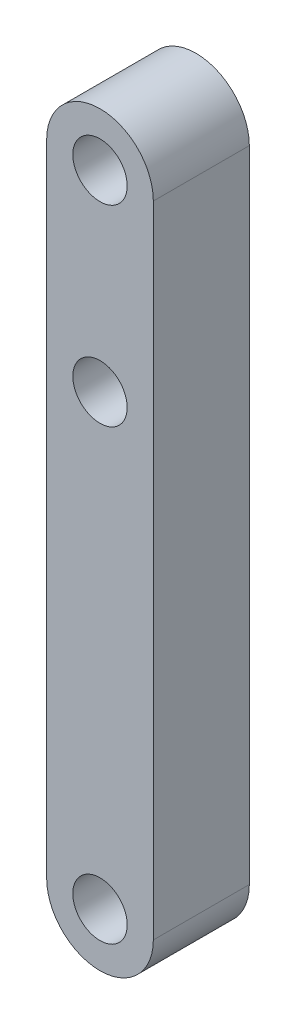
from build123d import *

# Parameters (mm, degrees)
BOSS_EXTRUDE1_DEPTH = 9
SKETCH2_R           = 2.55
CUT_EXTRUDE1_DEPTH  = 10


with BuildPart() as part:
    # Sketch1 → Boss-Extrude1 (new body)
    with BuildSketch(Plane.XY):
        with BuildLine():
            Line((-5, 0), (-5, -60))
            ThreePointArc((-5, -60), (0, -65), (5, -60))
            Line((5, -60), (5, 0))
            ThreePointArc((5, 0), (0, 5), (-5, 0))
        make_face()
    extrude(amount=BOSS_EXTRUDE1_DEPTH)

    # Sketch2 → Cut-Extrude1 (cut, through all)
    with BuildSketch(Plane.XY.offset(9)):
        Circle(SKETCH2_R)
        with Locations((0, -60)):
            Circle(SKETCH2_R)
        with Locations((0, -18)):
            Circle(SKETCH2_R)
    extrude(amount=-CUT_EXTRUDE1_DEPTH, mode=Mode.SUBTRACT)


solid = part.part
